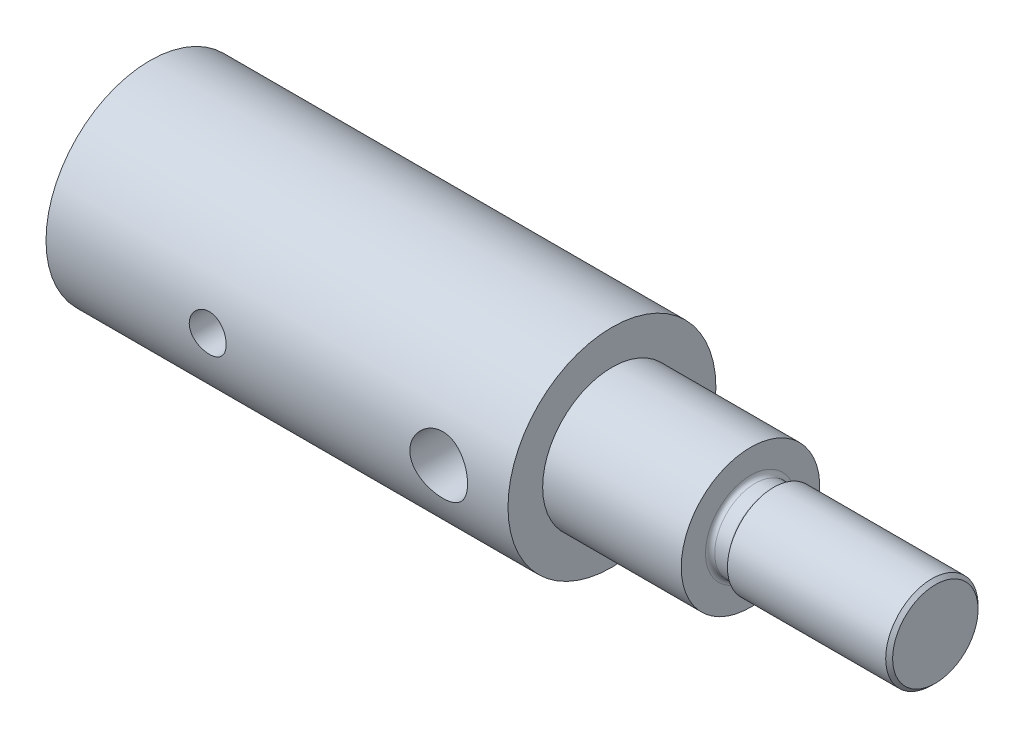
from build123d import *

# Parameters (mm, degrees)
FASE1_SIZE                           = 0.15
SKIZZE2_W                            = 1
SKIZZE2_H                            = 0.5
VERRUNDUNG1_R                        = 0.2
SKIZZE5_W                            = 0.8
SKIZZE5_H                            = 4.5
SKIZZE7_R                            = 1.25
SCHNITT_LINEAR_AUSTRAGEN2_DEPTH      = 5.50000011
SCHNITT_LINEAR_AUSTRAGEN2_DEPTH_BACK = 5.5000001


with BuildPart() as part:
    # Skizze1 → Rotation1 (revolve)
    with BuildSketch(Plane.XY):
        Polygon((0, 4.5), (0, 2), (14, 2), (15.201721238, 0), (34, 0), (34, 2), (26, 2), (26, 3), (20, 3), (20, 4.5), align=None)
    revolve(axis=Axis((0, 0, 0), (1, 0, 0)))

    # Fase1
    fase1_edges = [part.edges().sort_by_distance(p)[0] for p in [
        (34, -2, 0),
    ]]
    chamfer(fase1_edges, length=FASE1_SIZE)

    # Skizze2 → Schnitt-Rotation1 (revolve, cut)
    with BuildSketch(Plane.XY):
        with Locations((26.5, 2)):
            Rectangle(SKIZZE2_W, SKIZZE2_H)
    revolve(axis=Axis((0, 0, 0), (1, 0, 0)), mode=Mode.SUBTRACT)

    # Verrundung1
    verrundung1_edges = [part.edges().sort_by_distance(p)[0] for p in [
        (27, -1.75, 0),
        (26, -1.75, 0),
    ]]
    fillet(verrundung1_edges, radius=VERRUNDUNG1_R)

    # Skizze5 → M2 Gewindebohrung1 (revolve, cut)
    with BuildSketch(Plane.YZ.offset(7)):
        with Locations((0.4, 2.25)):
            Rectangle(SKIZZE5_W, SKIZZE5_H)
    revolve(axis=Axis((7, 0, -6.35), (0, 0, 1)), mode=Mode.SUBTRACT)

    # Skizze7 → Schnitt-Linear austragen2 (cut, two sides)
    with BuildSketch(Plane.XY) as schnitt_linear_austragen2_sk:
        with Locations((17, 0)):
            Circle(SKIZZE7_R)
    extrude(amount=SCHNITT_LINEAR_AUSTRAGEN2_DEPTH, mode=Mode.SUBTRACT)
    extrude(schnitt_linear_austragen2_sk.sketch, amount=-SCHNITT_LINEAR_AUSTRAGEN2_DEPTH_BACK, mode=Mode.SUBTRACT)


solid = part.part
